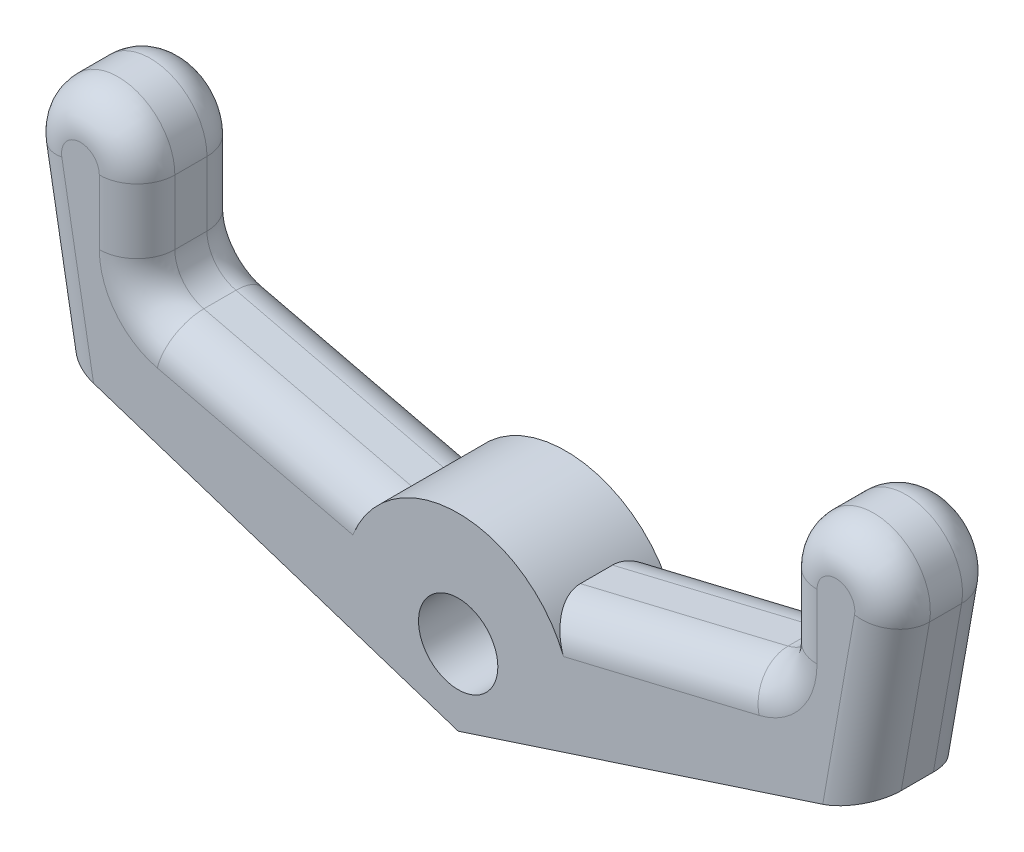
from build123d import *

# Parameters (mm, degrees)
SKETCH1_R           = 1.05
BOSS_EXTRUDE1_DEPTH = 2.85
FILLET2_R           = 1
FILLET1_R           = 1


with BuildPart() as part:
    # Sketch1 → Boss-Extrude1 (new body)
    with BuildSketch(Plane.XY):
        with BuildLine():
            Line((2.236067977, 2), (8.5, 3.5))
            Line((8.5, 3.5), (8.5, 6))
            ThreePointArc((8.5, 6), (10.130733614, 7.494292047), (11.47721163, 5.739527733))
            Line((11.47721163, 5.739527733), (10.729668505, 1.5))
            Line((10.729668505, 1.5), (0, -2))
            Line((0, -2), (-10.729668505, 1.5))
            Line((-10.729668505, 1.5), (-11.47721163, 5.739527733))
            ThreePointArc((-11.47721163, 5.739527733), (-10.130733614, 7.494292047), (-8.5, 6))
            Line((-8.5, 6), (-8.5, 3.5))
            Line((-8.5, 3.5), (-2.236067977, 2))
            ThreePointArc((-2.236067977, 2), (0, 3), (2.236067977, 2))
        make_face()
        Circle(SKETCH1_R, mode=Mode.SUBTRACT)
    extrude(amount=BOSS_EXTRUDE1_DEPTH)

    # Fillet2
    fillet2_edges = [part.edges().sort_by_distance(p)[0] for p in [
        (8.5, 3.5, 1.425),
        (-8.5, 3.5, 1.425),
    ]]
    fillet(fillet2_edges, radius=FILLET2_R)

    # Fillet1
    fillet1_edges = [part.edges().sort_by_distance(p)[0] for p in [
        (8.5, 5.144403083, 0),
        (10.130733614, 7.494292047, 0),
        (11.103440067, 3.619763867, 0),
        (-11.103440067, 3.619763867, 0),
        (-10.130733614, 7.494292047, 0),
        (-10.130733614, 7.494292047, 2.85),
        (-4.984475025, 2.658150592, 0),
        (-11.103440067, 3.619763867, 2.85),
        (11.103440067, 3.619763867, 2.85),
        (10.130733614, 7.494292047, 2.85),
        (8.5, 5.144403083, 2.85),
        (-8.5, 5.144403083, 0),
        (-8.5, 5.144403083, 2.85),
        (4.984475025, 2.658150592, 0),
        (4.984475025, 2.658150592, 2.85),
        (-8.285137591, 3.669484793, 0),
        (-8.285137591, 3.669484793, 2.85),
        (8.285137591, 3.669484793, 0),
        (8.285137591, 3.669484793, 2.85),
        (-4.984475025, 2.658150592, 2.85),
    ]]
    fillet(fillet1_edges, radius=FILLET1_R)


solid = part.part
